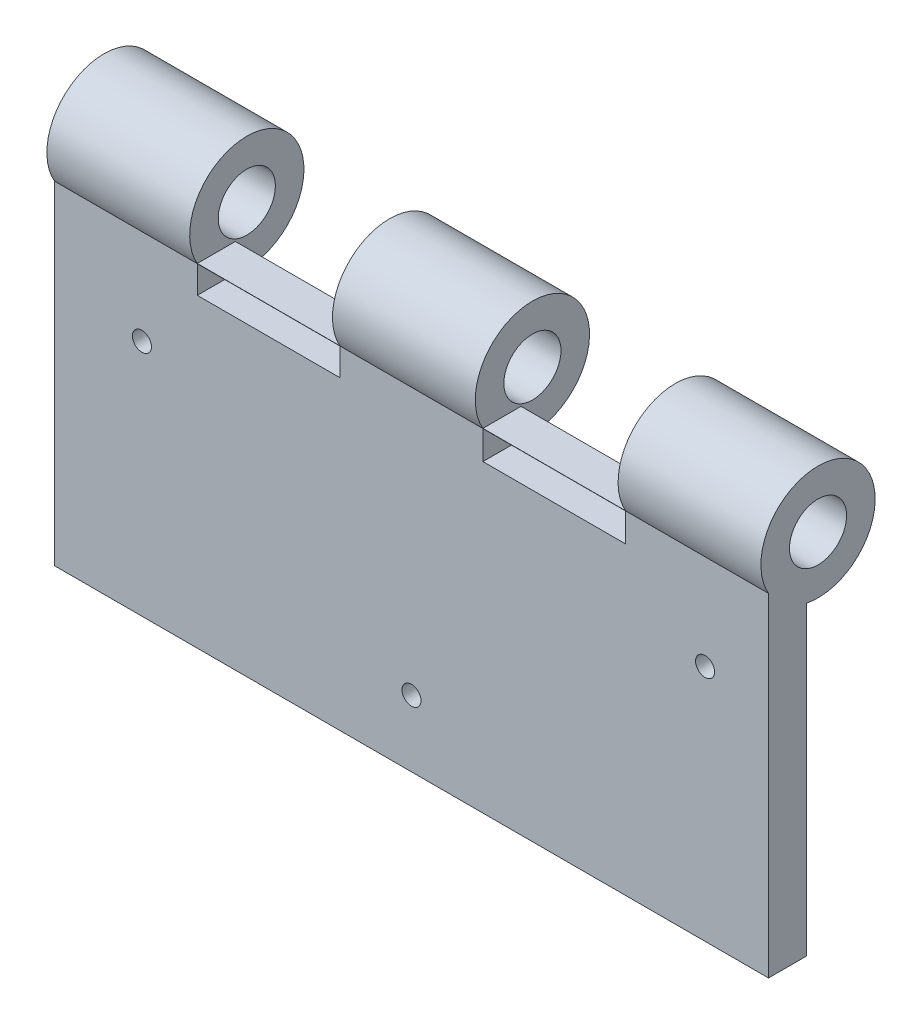
from build123d import *

# Parameters (mm, degrees)
SKETCH1_W           = 150
SKETCH1_H           = 70
BOSS_EXTRUDE1_DEPTH = 4
SKETCH4_R           = 12
SKETCH4_R_2         = 6
BOSS_EXTRUDE6_DEPTH = 30
LPATTERN1_COUNT     = 3
LPATTERN1_PITCH     = 60
SKETCH7_R           = 2
CUT_EXTRUDE2_DEPTH  = 30
CHAMFER3_SIZE       = 4
SKETCH8_W           = 30
SKETCH8_H           = 6
CUT_EXTRUDE3_DEPTH  = 10
SKETCH9_W           = 30
SKETCH9_H           = 5.757460858
CUT_EXTRUDE4_DEPTH  = 10


with BuildPart() as part:
    # Sketch1 → Boss-Extrude1 (new body, symmetric)
    with BuildSketch(Plane.XY):
        Rectangle(SKETCH1_W, SKETCH1_H)
    extrude(amount=BOSS_EXTRUDE1_DEPTH, both=True)

    # Sketch4 → Boss-Extrude6 (add)
    with BuildSketch(Plane(origin=(75, 0, 0), x_dir=(0, 0, -1), z_dir=(1, 0, 0))):
        with Locations((6.400440408, 40.953753189)):
            Circle(SKETCH4_R)
        with Locations((6.400440408, 40.953753189)):
            Circle(SKETCH4_R_2, mode=Mode.SUBTRACT)
    boss_extrude6 = extrude(amount=-BOSS_EXTRUDE6_DEPTH)

    # LPattern1: Boss-Extrude6 ×3
    with Locations(*[(-i * LPATTERN1_PITCH, 0, 0) for i in range(1, LPATTERN1_COUNT)]):
        add(boss_extrude6)

    # Sketch7 → Cut-Extrude2 (cut)
    with BuildSketch(Plane.XY.offset(4)):
        with Locations((-56.630501899, 15.015863732)):
            Circle(SKETCH7_R)
        with Locations((0, -21.058085924)):
            Circle(SKETCH7_R)
        with Locations((61.669656729, 15.015863732)):
            Circle(SKETCH7_R)
    extrude(amount=-CUT_EXTRUDE2_DEPTH, mode=Mode.SUBTRACT)

    # Chamfer3
    chamfer3_edges = [part.edges().sort_by_distance(p)[0] for p in [
        (-58.630501899, 15.015863732, -4),
        (-2, -21.058085924, -4),
        (59.669656729, 15.015863732, -4),
    ]]
    chamfer(chamfer3_edges, length=CHAMFER3_SIZE)

    # Sketch8 → Cut-Extrude3 (cut)
    with BuildSketch(Plane(origin=(0, 0, -4), x_dir=(-1, 0, 0), z_dir=(0, 0, -1))):
        with Locations((-30, 31.953753189)):
            Rectangle(SKETCH8_W, SKETCH8_H)
    extrude(amount=-CUT_EXTRUDE3_DEPTH, mode=Mode.SUBTRACT)

    # Sketch9 → Cut-Extrude4 (cut)
    with BuildSketch(Plane(origin=(0, 0, -4), x_dir=(-1, 0, 0), z_dir=(0, 0, -1))):
        with Locations((30, 32.07502276)):
            Rectangle(SKETCH9_W, SKETCH9_H)
    extrude(amount=-CUT_EXTRUDE4_DEPTH, mode=Mode.SUBTRACT)


solid = part.part
